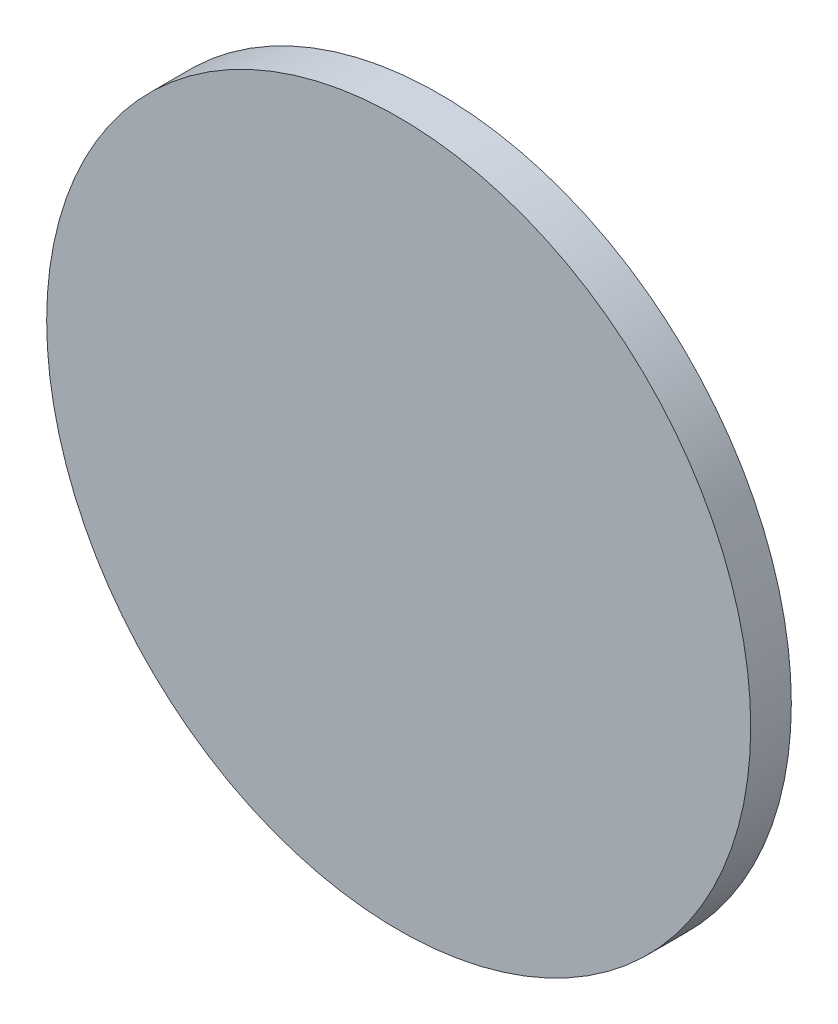
from build123d import *

# Parameters (mm, degrees)
SKETCH1_R           = 330.2
BOSS_EXTRUDE1_DEPTH = 38.1


with BuildPart() as part:
    # Sketch1 → Boss-Extrude1 (new body)
    with BuildSketch(Plane.XY):
        Circle(SKETCH1_R)
    extrude(amount=BOSS_EXTRUDE1_DEPTH)


solid = part.part
